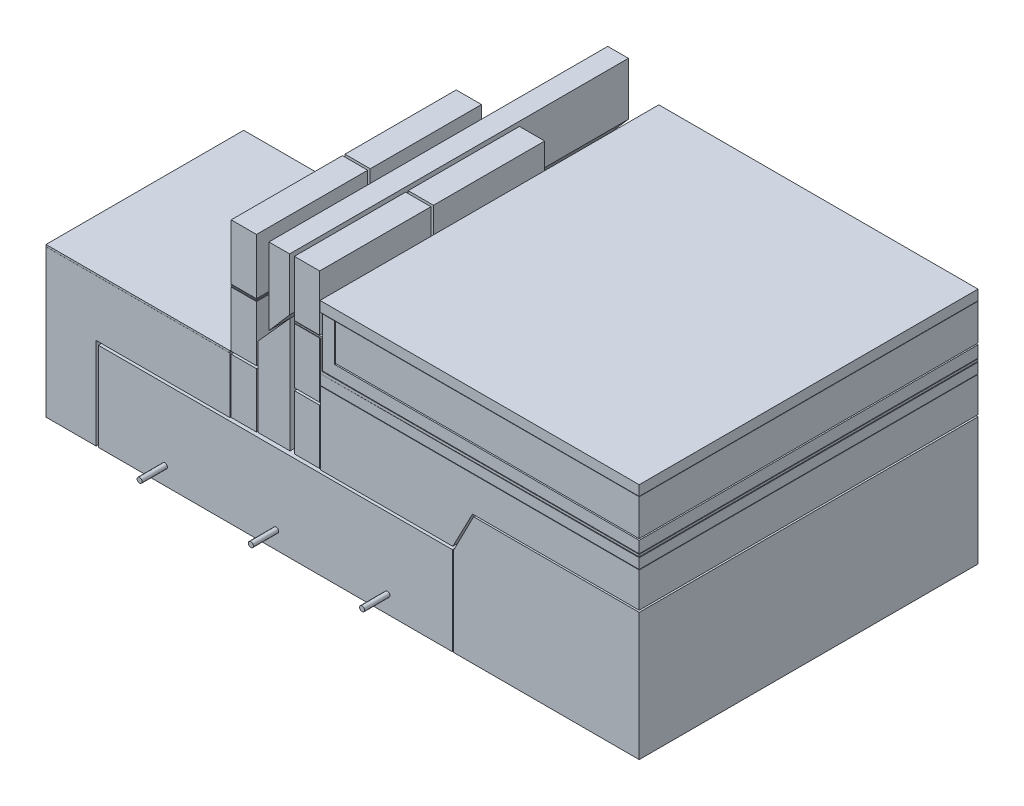
from build123d import *

# Parameters (mm, degrees)
SKETCH2_W         = 100
SKETCH2_H         = 216.893893569
EXTRUDE2_DEPTH    = 440
EXTRUDE2_2_DEPTH  = 440
SKETCH3_W         = 440
SKETCH3_H         = 220
EXTRUDE3_DEPTH    = 100
EXTRUDE3_2_DEPTH  = 100
SKETCH4_W         = 440
SKETCH4_H         = 220
EXTRUDE4_DEPTH    = 100
EXTRUDE4_2_DEPTH  = 100
SKETCH6_W         = 215
SKETCH6_H         = 220
EXTRUDE6_DEPTH    = 100
SKETCH6_W_2       = 445.705034037
EXTRUDE6_2_DEPTH  = 100
SKETCH6_W_3       = 440
EXTRUDE6_3_DEPTH  = 100
SKETCH7_W         = 215
SKETCH7_H         = 220
EXTRUDE7_DEPTH    = 100
SKETCH7_W_2       = 445.705034037
EXTRUDE7_2_DEPTH  = 100
SKETCH7_W_3       = 440
EXTRUDE7_3_DEPTH  = 100
SKETCH8_W         = 440
SKETCH8_H         = 220
EXTRUDE8_DEPTH    = 100
EXTRUDE8_2_DEPTH  = 100
SKETCH9_W         = 440
SKETCH9_H         = 220
EXTRUDE9_DEPTH    = 100
EXTRUDE9_2_DEPTH  = 100
SKETCH10_R        = 10
EXTRUDE10_DEPTH   = 100
EXTRUDE10_2_DEPTH = 100
EXTRUDE10_3_DEPTH = 100
EXTRUDE11_DEPTH   = 1340
EXTRUDE12_DEPTH   = 1340
EXTRUDE13_DEPTH   = 1340
SKETCH25_W        = 1260.140608633
SKETCH25_H        = 40
EXTRUDE24_DEPTH   = 1340
EXTRUDE25_DEPTH   = 1340
SKETCH19_W        = 100.016924429
SKETCH19_H        = 4.415976872
EXTRUDE26_DEPTH   = 1120.705034
EXTRUDE27_DEPTH   = 1340
SKETCH28_W        = 1201.259125171
SKETCH28_H        = 143.56794446
EXTRUDE28_DEPTH   = 1340
SKETCH29_W        = 1262.434466765
SKETCH29_H        = 40
EXTRUDE29_DEPTH   = 1340
SKETCH20_W        = 1400
SKETCH20_H        = 350
EXTRUDE20_DEPTH   = 1400
EXTRUDE21_DEPTH   = 782
SKETCH22_W        = 727.302372543
SKETCH22_H        = 7.665581987
EXTRUDE22_DEPTH   = 782
EXTRUDE23_DEPTH   = 1340


with BuildPart() as part:
    # Sketch2 → Extrude2 (new body)
    with BuildSketch(Plane.XY):
        with Locations((-650, 473.646207299)):
            Rectangle(SKETCH2_W, SKETCH2_H)
    extrude(amount=-EXTRUDE2_DEPTH)


with BuildPart() as body_2:
    # Sketch2 → Extrude2 2 (new body)
    with BuildSketch(Plane.XY):
        with Locations((-400, 473.646207299)):
            Rectangle(SKETCH2_W, SKETCH2_H)
    extrude(amount=-EXTRUDE2_2_DEPTH)


with BuildPart() as body_3:
    # Sketch3 → Extrude3 (new body)
    with BuildSketch(Plane.ZY.offset(700)):
        with Locations((-670, 472.093154083)):
            Rectangle(SKETCH3_W, SKETCH3_H)
    extrude(amount=-EXTRUDE3_DEPTH)


with BuildPart() as body_4:
    # Sketch3 → Extrude3 2 (new body)
    with BuildSketch(Plane.ZY.offset(700)):
        with Locations((-1120, 472.093154083)):
            Rectangle(SKETCH3_W, SKETCH3_H)
    extrude(amount=-EXTRUDE3_2_DEPTH)


with BuildPart() as body_5:
    # Sketch4 → Extrude4 (new body)
    with BuildSketch(Plane(origin=(-350, 0, 0), x_dir=(0, 0, -1), z_dir=(1, 0, 0))):
        with Locations((670, 472.093154083)):
            Rectangle(SKETCH4_W, SKETCH4_H)
    extrude(amount=-EXTRUDE4_DEPTH)


with BuildPart() as body_6:
    # Sketch4 → Extrude4 2 (new body)
    with BuildSketch(Plane(origin=(-350, 0, 0), x_dir=(0, 0, -1), z_dir=(1, 0, 0))):
        with Locations((1120, 472.093154083)):
            Rectangle(SKETCH4_W, SKETCH4_H)
    extrude(amount=-EXTRUDE4_2_DEPTH)


with BuildPart() as body_7:
    # Sketch6 → Extrude6 (new body)
    with BuildSketch(Plane.ZY.offset(700)):
        with Locations((-107.5, 702.093154083)):
            Rectangle(SKETCH6_W, SKETCH6_H)
    extrude(amount=-EXTRUDE6_DEPTH)


with BuildPart() as body_8:
    # Sketch6 → Extrude6 2 (new body)
    with BuildSketch(Plane.ZY.offset(700)):
        with Locations((-447.852517019, 702.093154083)):
            Rectangle(SKETCH6_W_2, SKETCH6_H)
    extrude(amount=-EXTRUDE6_2_DEPTH)


with BuildPart() as body_9:
    # Sketch6 → Extrude6 3 (new body)
    with BuildSketch(Plane.ZY.offset(700)):
        with Locations((-900.705034037, 702.093154083)):
            Rectangle(SKETCH6_W_3, SKETCH6_H)
    extrude(amount=-EXTRUDE6_3_DEPTH)


with BuildPart() as body_10:
    # Sketch7 → Extrude7 (new body)
    with BuildSketch(Plane(origin=(-350, 0, 0), x_dir=(0, 0, -1), z_dir=(1, 0, 0))):
        with Locations((107.5, 702.093154083)):
            Rectangle(SKETCH7_W, SKETCH7_H)
    extrude(amount=-EXTRUDE7_DEPTH)


with BuildPart() as body_11:
    # Sketch7 → Extrude7 2 (new body)
    with BuildSketch(Plane(origin=(-350, 0, 0), x_dir=(0, 0, -1), z_dir=(1, 0, 0))):
        with Locations((447.852517019, 702.093154083)):
            Rectangle(SKETCH7_W_2, SKETCH7_H)
    extrude(amount=-EXTRUDE7_2_DEPTH)


with BuildPart() as body_12:
    # Sketch7 → Extrude7 3 (new body)
    with BuildSketch(Plane(origin=(-350, 0, 0), x_dir=(0, 0, -1), z_dir=(1, 0, 0))):
        with Locations((900.705034037, 702.093154083)):
            Rectangle(SKETCH7_W_3, SKETCH7_H)
    extrude(amount=-EXTRUDE7_3_DEPTH)


with BuildPart() as body_13:
    # Sketch8 → Extrude8 (new body)
    with BuildSketch(Plane.ZY.offset(700)):
        with Locations((-220, 932.093154083)):
            Rectangle(SKETCH8_W, SKETCH8_H)
    extrude(amount=-EXTRUDE8_DEPTH)


with BuildPart() as body_14:
    # Sketch8 → Extrude8 2 (new body)
    with BuildSketch(Plane.ZY.offset(700)):
        with Locations((-670, 932.093154083)):
            Rectangle(SKETCH8_W, SKETCH8_H)
    extrude(amount=-EXTRUDE8_2_DEPTH)


with BuildPart() as body_15:
    # Sketch9 → Extrude9 (new body)
    with BuildSketch(Plane(origin=(-350, 0, 0), x_dir=(0, 0, -1), z_dir=(1, 0, 0))):
        with Locations((220, 932.093154083)):
            Rectangle(SKETCH9_W, SKETCH9_H)
    extrude(amount=-EXTRUDE9_DEPTH)


with BuildPart() as body_16:
    # Sketch9 → Extrude9 2 (new body)
    with BuildSketch(Plane(origin=(-350, 0, 0), x_dir=(0, 0, -1), z_dir=(1, 0, 0))):
        with Locations((670, 932.093154083)):
            Rectangle(SKETCH9_W, SKETCH9_H)
    extrude(amount=-EXTRUDE9_2_DEPTH)


with BuildPart() as body_17:
    # Sketch10 → Extrude10 (new body)
    with BuildSketch(Plane.XY):
        with Locations((-962.14462561, 68.901890749)):
            Circle(SKETCH10_R)
    extrude(amount=EXTRUDE10_DEPTH)



with BuildPart() as body_18:
    # Sketch10 → Extrude10 2 (new body)
    with BuildSketch(Plane.XY):
        with Locations((-522.14462561, 68.901890749)):
            Circle(SKETCH10_R)
    extrude(amount=EXTRUDE10_2_DEPTH)


with BuildPart() as body_19:
    # Sketch10 → Extrude10 3 (new body)
    with BuildSketch(Plane.XY):
        with Locations((-82.14462561, 68.901890749)):
            Circle(SKETCH10_R)
    extrude(amount=EXTRUDE10_3_DEPTH)


with BuildPart() as body_20:
    # Sketch11 → Extrude11 (new body)
    with BuildSketch(Plane.XY):
        Polygon((-467.142623081, 366.760238591), (-467.142623081, 821.047790695), (-593.71305263, 680.021419663), (-593.71305263, 366.760238591), align=None)
    extrude(amount=-EXTRUDE11_DEPTH)


with BuildPart() as body_21:
    # Sketch12 → Extrude12 (new body)
    with BuildSketch(Plane.XY):
        Polygon((-468.887831959, 831.987849689), (-468.887831959, 1040.989689962), (-550.716667875, 1040.989689962), (-550.716667875, 737.60580318), align=None)
    extrude(amount=-EXTRUDE12_DEPTH)


with BuildPart() as body_22:
    # Sketch13 → Extrude13 (new body)
    with BuildSketch(Plane.XY):
        Polygon((-336.360440611, 649.537526022), (-346.269121555, 649.537526022), (-346.269121555, 361.986236304), (176.578189157, 361.986236304), (254.472464788, 511.620468575), (913.666899137, 511.620468575), (913.666899137, 649.537526022), align=None)
    extrude(amount=-EXTRUDE13_DEPTH)


with BuildPart() as body_23:
    # Sketch25 → Extrude24 (new body)
    with BuildSketch(Plane.XY):
        with Locations((283.705750796, 671.510678423)):
            Rectangle(SKETCH25_W, SKETCH25_H)
    extrude(amount=-EXTRUDE24_DEPTH)


with BuildPart() as body_24:
    # Sketch26 → Extrude25 (new body)
    with BuildSketch(Plane.XY):
        Polygon((-450, 820.128969283), (-341.131314593, 820.128969283), (-341.131314593, 702.66723663), (913.776055112, 702.66723663), (913.776055112, 694.7291903), (-346.364553521, 691.510678423), (-346.364553521, 814.220916483), (-450, 814.220916483), align=None)
    extrude(amount=-EXTRUDE25_DEPTH)


with BuildPart() as body_25:
    # Sketch19 → Extrude26 (new body)
    with BuildSketch(Plane.XY):
        with Locations((-650.08879901, 817.553634615)):
            Rectangle(SKETCH19_W, SKETCH19_H)
    extrude(amount=-EXTRUDE26_DEPTH)


with BuildPart() as body_26:
    # Sketch27 → Extrude27 (new body)
    with BuildSketch(Plane.XY):
        Polygon((-291.105829066, 751.21682318), (-291.105829066, 900.362935748), (-339.162625663, 900.362935748), (-339.162625663, 705.194537611), (913.776055112, 705.194537611), (913.776055112, 751.21682318), align=None)
    extrude(amount=-EXTRUDE27_DEPTH)


with BuildPart() as body_27:
    # Sketch28 → Extrude28 (new body)
    with BuildSketch(Plane.XY):
        with Locations((313.146492527, 828.578963518)):
            Rectangle(SKETCH28_W, SKETCH28_H)
    extrude(amount=-EXTRUDE28_DEPTH)


with BuildPart() as body_28:
    # Sketch29 → Extrude29 (new body)
    with BuildSketch(Plane.XY):
        with Locations((282.55882173, 921.793873188)):
            Rectangle(SKETCH29_W, SKETCH29_H)
    extrude(amount=-EXTRUDE29_DEPTH)


with BuildPart() as body_17_1:
    add(body_17.part)

    add(body_18.part)  # Extrude20 merges body 18

    add(body_19.part)  # Extrude20 merges body 19
    # Sketch20 → Extrude20 (add)
    with BuildSketch(Plane.XY):
        with Locations((-525, 175)):
            Rectangle(SKETCH20_W, SKETCH20_H)
    extrude(amount=-EXTRUDE20_DEPTH)


with BuildPart() as body_27_2:
    # Sketch21 → Extrude21 (new body)
    with BuildSketch(Plane.XY):
        Polygon((-705.139160996, 362.026490626), (-705.139160996, 583.683564254), (-1432.468840189, 583.683564254), (-1432.468840189, 0), (-1234.131370773, 0), (-1234.131370773, 362.026490626), align=None)
    extrude(amount=-EXTRUDE21_DEPTH)


with BuildPart() as body_28_2:
    # Sketch22 → Extrude22 (new body)
    with BuildSketch(Plane.XY):
        with Locations((-1068.817653918, 587.719222247)):
            Rectangle(SKETCH22_W, SKETCH22_H)
    extrude(amount=-EXTRUDE22_DEPTH)


with BuildPart() as body_29:
    # Sketch24 → Extrude23 (new body)
    with BuildSketch(Plane.XY):
        Polygon((179.909512324, 0), (179.909512324, 350.525019172), (258.843038159, 504.423231818), (913.801722761, 504.423231818), (913.801722761, 0), align=None)
    extrude(amount=-EXTRUDE23_DEPTH)


solid = Compound([part.part, body_2.part, body_3.part, body_4.part, body_5.part, body_6.part, body_7.part, body_8.part, body_9.part, body_10.part, body_11.part, body_12.part, body_13.part, body_14.part, body_15.part, body_16.part, body_20.part, body_21.part, body_22.part, body_23.part, body_24.part, body_25.part, body_26.part, body_27.part, body_28.part, body_17_1.part, body_27_2.part, body_28_2.part, body_29.part])
